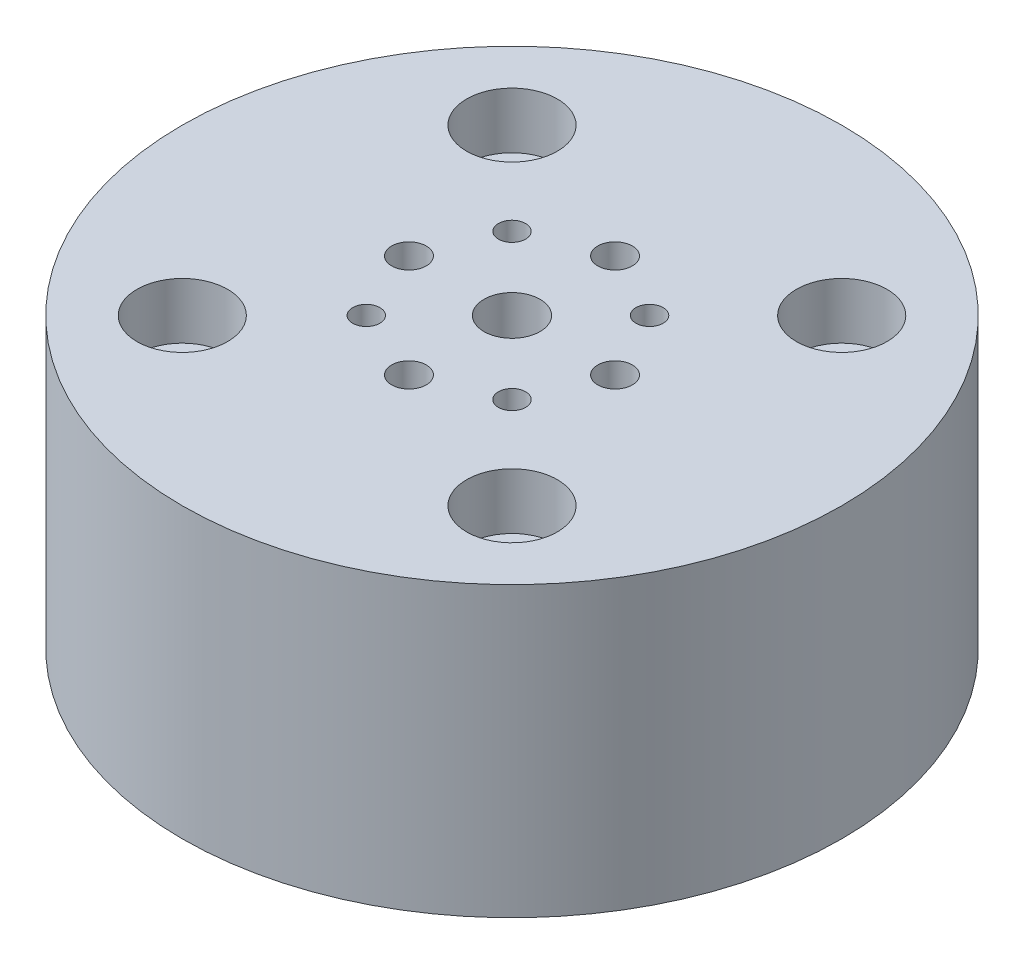
from build123d import *

# Parameters (mm, degrees)
SKETCH_1_R                = 40
EXTRUDE_1_DEPTH           = 35
HOLE_WIZARD_1_D           = 6.6
HOLE_WIZARD_1_DEPTH       = 50
HOLE_WIZARD_1_CBORE_D     = 11
HOLE_WIZARD_1_CBORE_DEPTH = 6.8
HOLE_WIZARD_1_TIP         = 1.982840043
HOLE_WIZARD_M5_1_D        = 4.2
HOLE_WIZARD_M5_1_DEPTH    = 12.4
HOLE_WIZARD_M5_1_TIP      = 1.2618073
HOLE_WIZARD_M4_1_D        = 3.3
HOLE_WIZARD_M4_1_DEPTH    = 10.1
HOLE_WIZARD_M4_1_TIP      = 0.991420021
HOLE_WIZARD_M8_1_D        = 6.8
HOLE_WIZARD_M8_1_DEPTH    = 19.75
HOLE_WIZARD_M8_1_TIP      = 2.042926105
SKETCH_7_R                = 2.065
CUT_EXTRUDE_1_DEPTH       = 40


with BuildPart() as part:
    # 草图1 → 凸台-拉伸1 (new body)
    with BuildSketch(Plane(origin=(0, 0, 0), x_dir=(1, 0, 0), z_dir=(0, 1, 0))):
        Circle(SKETCH_1_R)
    extrude(amount=EXTRUDE_1_DEPTH)

    # 打孔尺寸(%根据)内六角圆柱头螺钉的类型1
    with Locations(Plane(origin=(-20, 35, -20), x_dir=(0, 0, 1), z_dir=(0, 1, 0))):
        with Locations((0, 0), (0, 40), (40, 40), (40, 0)):
            CounterBoreHole(HOLE_WIZARD_1_D / 2, HOLE_WIZARD_1_CBORE_D / 2, HOLE_WIZARD_1_CBORE_DEPTH, depth=HOLE_WIZARD_1_DEPTH)
            with Locations((0, 0, -(HOLE_WIZARD_1_DEPTH + HOLE_WIZARD_1_TIP / 2))):  # 118° drill point
                Cone(0, HOLE_WIZARD_1_D / 2, HOLE_WIZARD_1_TIP, mode=Mode.SUBTRACT)

    # M5 螺纹孔1
    with Locations(Plane(origin=(0, 35, -12.5), x_dir=(0, 0, 1), z_dir=(0, 1, 0))):
        with Locations((0, 0), (25, 0), (12.5, 12.5), (12.5, -12.5)):
            Hole(HOLE_WIZARD_M5_1_D / 2, depth=HOLE_WIZARD_M5_1_DEPTH)
            with Locations((0, 0, -(HOLE_WIZARD_M5_1_DEPTH + HOLE_WIZARD_M5_1_TIP / 2))):  # 118° drill point
                Cone(0, HOLE_WIZARD_M5_1_D / 2, HOLE_WIZARD_M5_1_TIP, mode=Mode.SUBTRACT)

    # M4 螺纹孔1
    with Locations(Plane(origin=(-8.838834765, 35, -8.838834765), x_dir=(0, 0, 1), z_dir=(0, 1, 0))):
        with Locations((0, 0), (0.495114697, 17.182554833), (17.67766953, 17.67766953), (17.67766953, 0)):
            Hole(HOLE_WIZARD_M4_1_D / 2, depth=HOLE_WIZARD_M4_1_DEPTH)
            with Locations((0, 0, -(HOLE_WIZARD_M4_1_DEPTH + HOLE_WIZARD_M4_1_TIP / 2))):  # 118° drill point
                Cone(0, HOLE_WIZARD_M4_1_D / 2, HOLE_WIZARD_M4_1_TIP, mode=Mode.SUBTRACT)

    # M8 螺纹孔1
    with Locations(Plane.ZX.offset(35)):
        with Locations((0, 0)):
            Hole(HOLE_WIZARD_M8_1_D / 2, depth=HOLE_WIZARD_M8_1_DEPTH)
            with Locations((0, 0, -(HOLE_WIZARD_M8_1_DEPTH + HOLE_WIZARD_M8_1_TIP / 2))):  # 118° drill point
                Cone(0, HOLE_WIZARD_M8_1_D / 2, HOLE_WIZARD_M8_1_TIP, mode=Mode.SUBTRACT)

    # 草图7 → 切除-拉伸1 (cut)
    with BuildSketch(Plane(origin=(-15.307337295, 35, -36.9551813), x_dir=(-0.923879533, 0, 0.382683432), z_dir=(-0.382683432, 0, -0.923879533))):
        with Locations((0, -10)):
            Circle(SKETCH_7_R)
    extrude(amount=-CUT_EXTRUDE_1_DEPTH, mode=Mode.SUBTRACT)


solid = part.part
